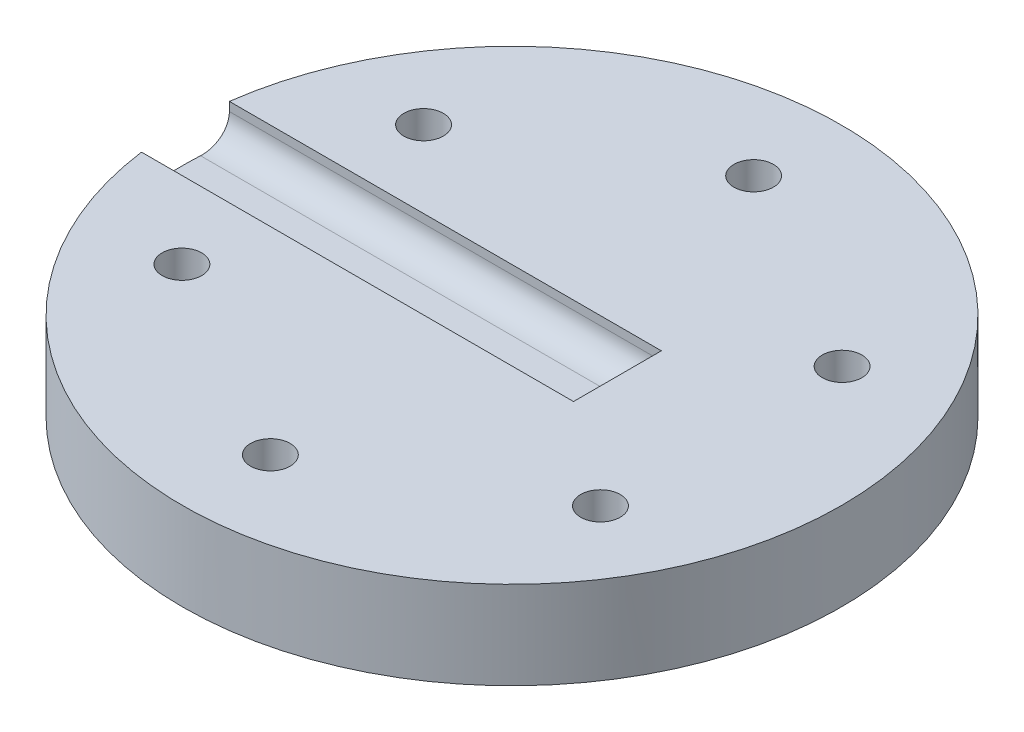
from build123d import *

# Parameters (mm, degrees)
SKETCH1_R           = 37.5
SKETCH1_R_2         = 2.25
BOSS_EXTRUDE1_DEPTH = 10
CUT_EXTRUDE1_DEPTH  = 4
FILLET1_R           = 3


with BuildPart() as part:
    # Sketch1 → Boss-Extrude1 (new body)
    with BuildSketch(Plane(origin=(0, 0, 0), x_dir=(1, 0, 0), z_dir=(0, 1, 0))):
        Circle(SKETCH1_R)
        with Locations((0, 27.5)):
            Circle(SKETCH1_R_2, mode=Mode.SUBTRACT)
        with Locations((23.815698604, 13.75)):
            Circle(SKETCH1_R_2, mode=Mode.SUBTRACT)
        with Locations((23.815698604, -13.75)):
            Circle(SKETCH1_R_2, mode=Mode.SUBTRACT)
        with Locations((0, -27.5)):
            Circle(SKETCH1_R_2, mode=Mode.SUBTRACT)
        with Locations((-23.815698604, -13.75)):
            Circle(SKETCH1_R_2, mode=Mode.SUBTRACT)
        with Locations((-23.815698604, 13.75)):
            Circle(SKETCH1_R_2, mode=Mode.SUBTRACT)
    extrude(amount=BOSS_EXTRUDE1_DEPTH)

    # Sketch2 → Cut-Extrude1 (cut)
    with BuildSketch(Plane(origin=(0, 10, 0), x_dir=(1, 0, 0), z_dir=(0, 1, 0))):
        with BuildLine():
            Line((12, -5), (12, 0))
            Line((12, 0), (12, 5))
            Line((12, 5), (-37.165171868, 5))
            ThreePointArc((-37.165171868, 5), (-37.5, 0), (-37.165171868, -5))
            Line((-37.165171868, -5), (12, -5))
        make_face()
    extrude(amount=-CUT_EXTRUDE1_DEPTH, mode=Mode.SUBTRACT)

    # Fillet1
    fillet1_edges = [part.edges().sort_by_distance(p)[0] for p in [
        (-12.582585934, 6, -5),
        (12, 6, 0),
        (-12.582585934, 6, 5),
    ]]
    fillet(fillet1_edges, radius=FILLET1_R)


solid = part.part
